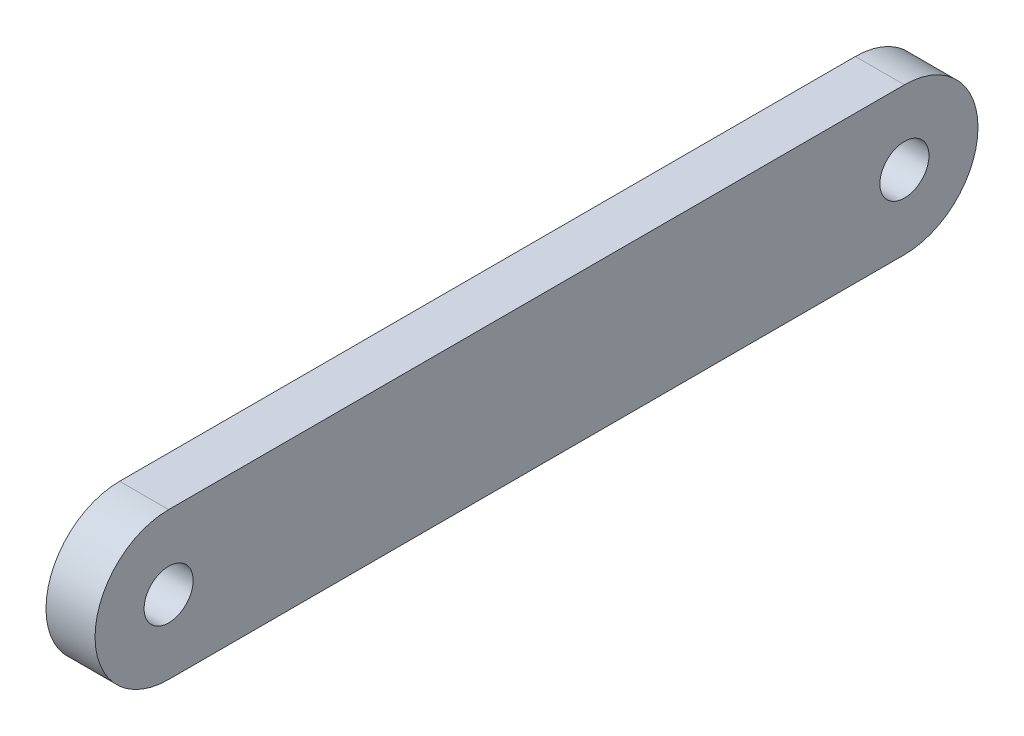
from build123d import *

# Parameters (mm, degrees)
SKETCH_1_W          = 10
SKETCH_1_H          = 180
EXTRUDE_1_DEPTH     = 30
SKETCH_3_R          = 5
CUT_EXTRUDE_3_DEPTH = 30


with BuildPart() as part:
    # Эскиз1 → Бобышка-Вытянуть1 (new body)
    with BuildSketch(Plane(origin=(0, 0, 0), x_dir=(1, 0, 0), z_dir=(0, 1, 0))):
        with Locations((32.217123935, 54.617723996)):
            Rectangle(SKETCH_1_W, SKETCH_1_H)
    extrude(amount=EXTRUDE_1_DEPTH)

    # Эскиз3 → Вырез-Вытянуть3 (cut)
    with BuildSketch(Plane(origin=(37.217123935, 0, 0), x_dir=(0, 0, -1), z_dir=(1, 0, 0))):
        with BuildLine():
            ThreePointArc((129.617723996, 30), (140.224325714, 25.606601718), (144.617723996, 15))
            Line((144.617723996, 15), (144.617723996, 30))
            Line((144.617723996, 30), (129.617723996, 30))
        make_face()
        with BuildLine():
            Line((129.617723996, 0), (144.617723996, 0))
            Line((144.617723996, 0), (144.617723996, 15))
            ThreePointArc((144.617723996, 15), (140.224325714, 4.393398282), (129.617723996, 0))
        make_face()
        with BuildLine():
            Line((-35.382276004, 0), (-20.382276004, 0))
            ThreePointArc((-20.382276004, 0), (-30.988877721, 4.393398282), (-35.382276004, 15))
            Line((-35.382276004, 15), (-35.382276004, 0))
        make_face()
        with BuildLine():
            ThreePointArc((-35.382276004, 15), (-30.988877721, 25.606601718), (-20.382276004, 30))
            Line((-20.382276004, 30), (-35.382276004, 30))
            Line((-35.382276004, 30), (-35.382276004, 15))
        make_face()
        with Locations((129.617723996, 15)):
            Circle(SKETCH_3_R)
        with Locations((-20.382276004, 15)):
            Circle(SKETCH_3_R)
    extrude(amount=-CUT_EXTRUDE_3_DEPTH, mode=Mode.SUBTRACT)


solid = part.part
